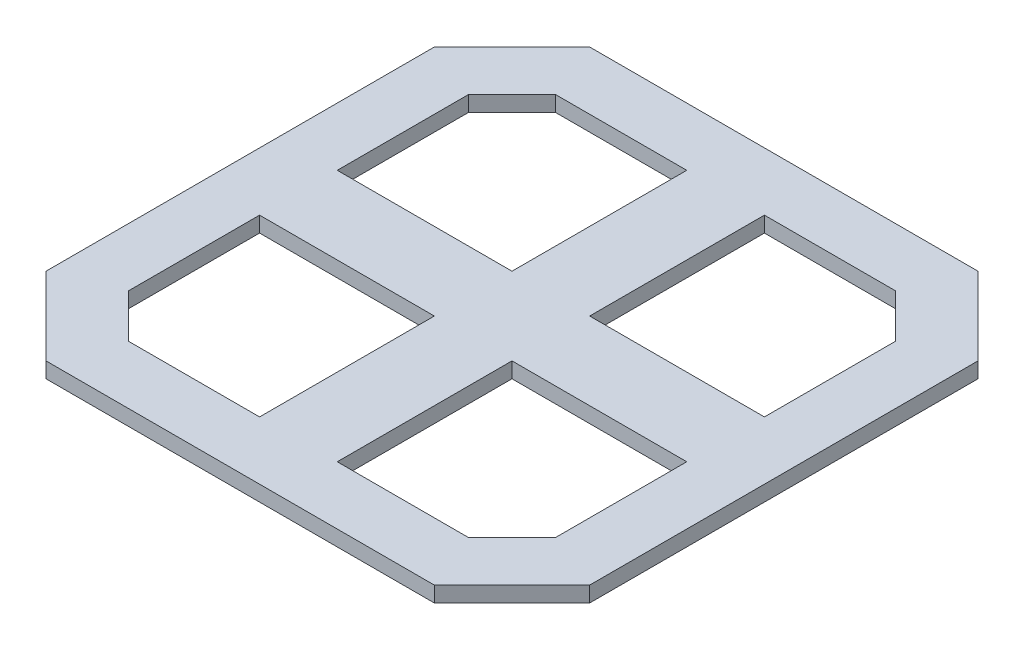
from build123d import *

# Parameters (mm, degrees)
SKETCH2_W           = 70
SKETCH2_H           = 70
BOSS_EXTRUDE1_DEPTH = 2
CUT_EXTRUDE1_DEPTH  = 2
CIRPATTERN1_COUNT   = 4


with BuildPart() as part:
    # Sketch2 → Boss-Extrude1 (new body)
    with BuildSketch(Plane(origin=(0, 0, 0), x_dir=(1, 0, 0), z_dir=(0, 1, 0))):
        Rectangle(SKETCH2_W, SKETCH2_H)
    extrude(amount=BOSS_EXTRUDE1_DEPTH)

    # Sketch4 → Cut-Extrude1 (cut)
    with BuildSketch(Plane.XZ):
        Polygon((25, 35), (35, 25), (35, 35), align=None)
        Polygon((21.893398282, 27.5), (27.5, 21.893398282), (27.5, 5), (5, 5), (5, 27.5), align=None)
    cut_extrude1 = extrude(amount=-CUT_EXTRUDE1_DEPTH, mode=Mode.SUBTRACT)

    # CirPattern1: Cut-Extrude1 ×4 about axis
    cirpattern1_axis = Axis((0, 0, 0), (0, 1, 0))
    for i in range(1, CIRPATTERN1_COUNT):
        add(cut_extrude1.rotate(cirpattern1_axis, i * 360 / CIRPATTERN1_COUNT), mode=Mode.SUBTRACT)


solid = part.part
